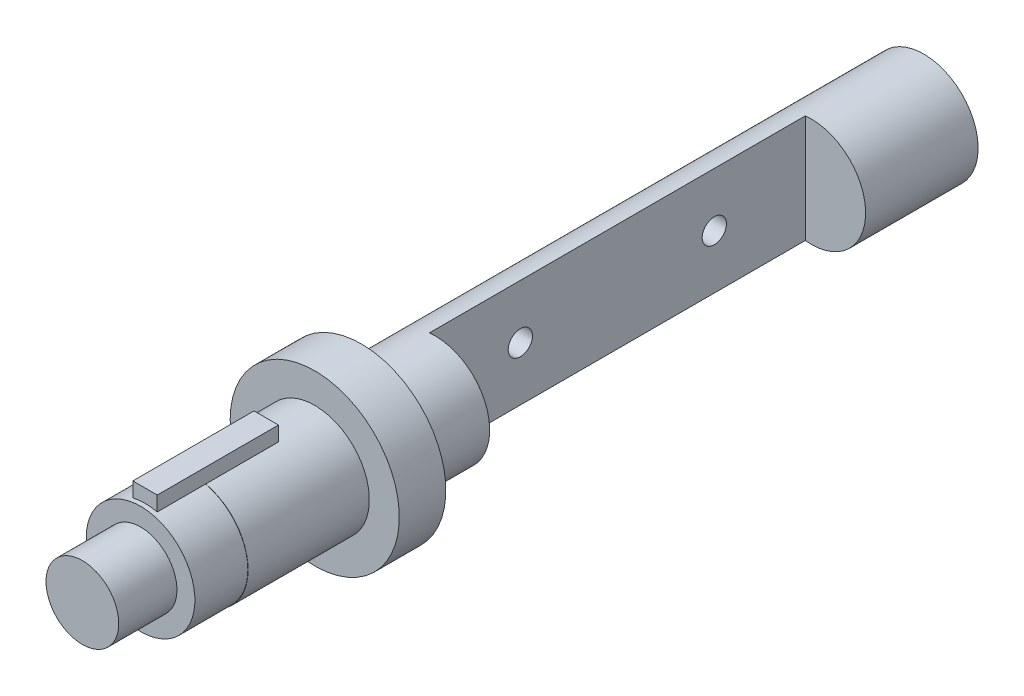
from build123d import *

# Parameters (mm, degrees)
SKETCH2_R               = 28.15
BOSS_EXTRUDE1_DEPTH     = 62.5
BOSS_EXTRUDE2_START     = 25
BOSS_EXTRUDE2_DEPTH     = 62.5
SKETCH5_W               = 31.1
SKETCH5_H               = 193.8
CUT_EXTRUDE1_DEPTH      = 44.6
CUT_EXTRUDE1_DEPTH_BACK = 44.6
SKETCH6_R               = 6.25
CUT_EXTRUDE2_DEPTH      = 41.5


with BuildPart() as part:
    # Sketch1 → Revolve1 (revolve)
    with BuildSketch(Plane(origin=(0, 0, 0), x_dir=(1, 0, 0), z_dir=(0, 1, 0))):
        Polygon((0, 0), (28, 0), (28, -290), (43.6, -290), (43.6, -314), (28, -314), (28, -403.8), (18.75, -403.8), (18.75, -433.8), (0, -433.8), align=None)
    revolve(axis=Axis((0, 0, 0), (0, 0, 1)))

    # Sketch2 → Boss-Extrude1 (add)
    with BuildSketch(Plane.XY.offset(314)):
        Circle(SKETCH2_R)
    extrude(amount=BOSS_EXTRUDE1_DEPTH)

    # Sketch3 → Boss-Extrude2 (add)
    with BuildSketch(Plane.XY.offset(314).offset(BOSS_EXTRUDE2_START)):
        with BuildLine():
            Line((-6.3, 35), (6.3, 35))
            Line((6.3, 35), (6.3, 27.435970914))
            ThreePointArc((6.3, 27.435970914), (0, 28.15), (-6.3, 27.435970914))
            Line((-6.3, 27.435970914), (-6.3, 35))
        make_face()
    extrude(amount=BOSS_EXTRUDE2_DEPTH)

    # Sketch5 → Cut-Extrude1 (cut, two sides)
    with BuildSketch(Plane(origin=(0, 0, 0), x_dir=(1, 0, 0), z_dir=(0, 1, 0))) as cut_extrude1_sk:
        with Locations((12.45, -154.9)):
            Rectangle(SKETCH5_W, SKETCH5_H)
    extrude(amount=CUT_EXTRUDE1_DEPTH, mode=Mode.SUBTRACT)
    extrude(cut_extrude1_sk.sketch, amount=-CUT_EXTRUDE1_DEPTH_BACK, mode=Mode.SUBTRACT)

    # Sketch6 → Cut-Extrude2 (cut, through all)
    with BuildSketch(Plane(origin=(-3.1, 0, 0), x_dir=(0, 0, -1), z_dir=(1, 0, 0))):
        with Locations((-204.9, 0)):
            Circle(SKETCH6_R)
        with Locations((-104.9, 0)):
            Circle(SKETCH6_R)
    extrude(amount=-CUT_EXTRUDE2_DEPTH, mode=Mode.SUBTRACT)


solid = part.part
